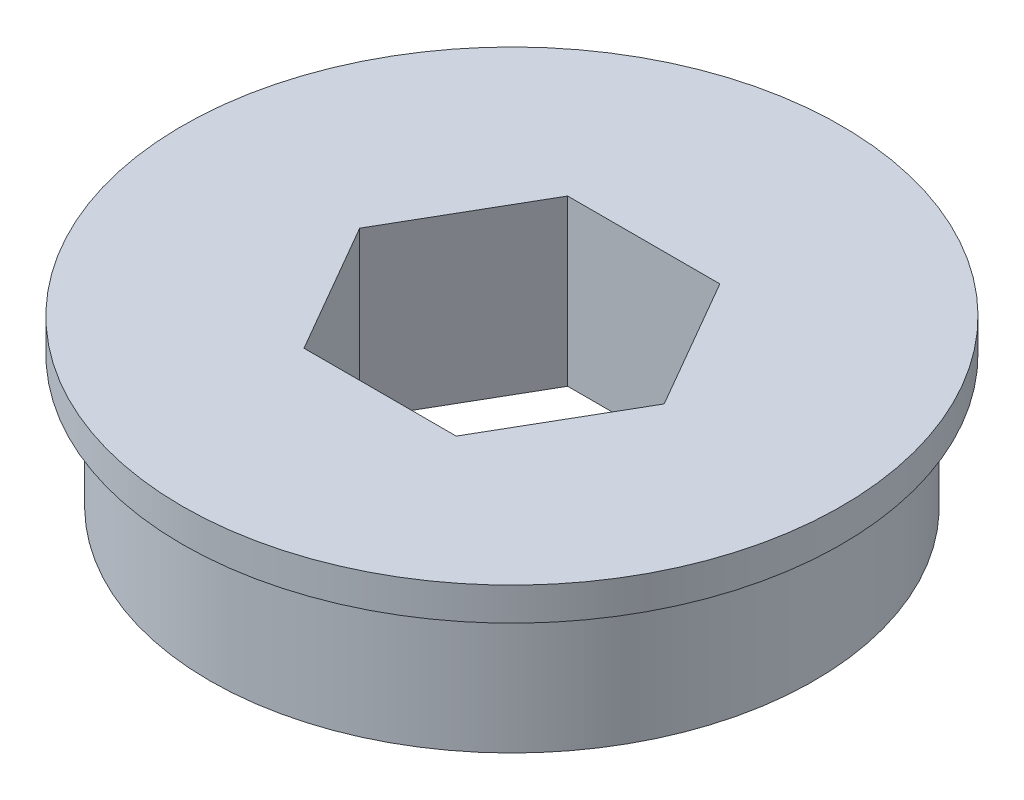
from build123d import *

# Parameters (mm, degrees)
SKETCH1_R           = 14.5542
BOSS_EXTRUDE1_DEPTH = 6.35
SKETCH2_R           = 15.875
BOSS_EXTRUDE2_DEPTH = 1.5875


with BuildPart() as part:
    # Sketch1 → Boss-Extrude1 (new body)
    with BuildSketch(Plane(origin=(0, 0, 0), x_dir=(1, 0, 0), z_dir=(0, 1, 0))):
        Circle(SKETCH1_R)
        Polygon((3.666174209, 6.35), (-3.666174209, 6.35), (-7.332348419, 0), (-3.666174209, -6.35), (3.666174209, -6.35), (7.332348419, 0), align=None, mode=Mode.SUBTRACT)
    extrude(amount=BOSS_EXTRUDE1_DEPTH)

    # Sketch2 → Boss-Extrude2 (add)
    with BuildSketch(Plane(origin=(0, 6.35, 0), x_dir=(1, 0, 0), z_dir=(0, 1, 0))):
        Circle(SKETCH2_R)
        Polygon((3.666174209, 6.35), (-3.666174209, 6.35), (-7.332348419, 0), (-3.666174209, -6.35), (3.666174209, -6.35), (7.332348419, 0), align=None, mode=Mode.SUBTRACT)
    extrude(amount=BOSS_EXTRUDE2_DEPTH)


solid = part.part
